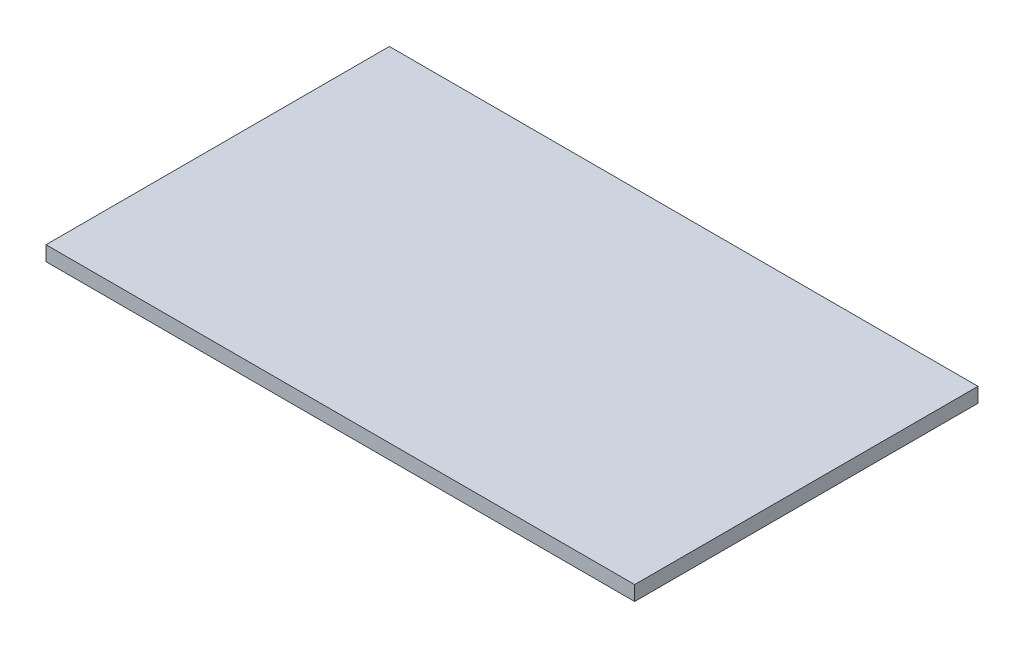
from build123d import *

# Parameters (mm, degrees)
SKETCH1_W           = 609.6
SKETCH1_H           = 355.6
BOSS_EXTRUDE1_DEPTH = 15.24


with BuildPart() as part:
    # Sketch1 → Boss-Extrude1 (new body)
    with BuildSketch(Plane(origin=(0, 0, 0), x_dir=(1, 0, 0), z_dir=(0, 1, 0))):
        with Locations((304.8, 177.8)):
            Rectangle(SKETCH1_W, SKETCH1_H)
    extrude(amount=BOSS_EXTRUDE1_DEPTH)


solid = part.part
